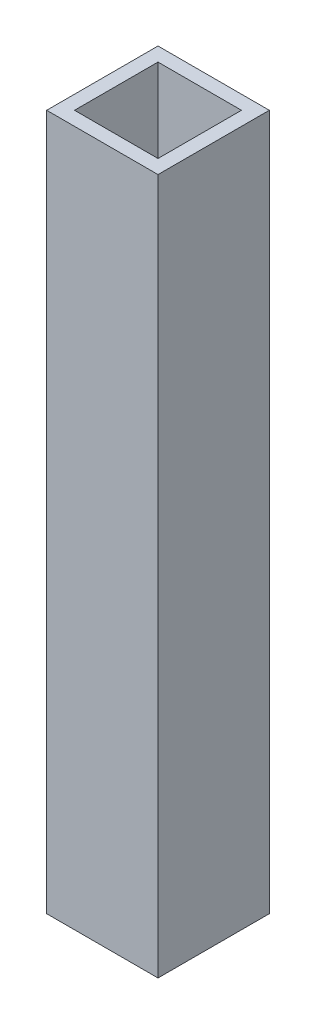
from build123d import *

# Parameters (mm, degrees)
SKETCH1_W           = 40
SKETCH1_H           = 40
SKETCH1_W_2         = 30
SKETCH1_H_2         = 30
BOSS_EXTRUDE1_DEPTH = 250


with BuildPart() as part:
    # Sketch1 → Boss-Extrude1 (new body)
    with BuildSketch(Plane(origin=(0, 0, 0), x_dir=(1, 0, 0), z_dir=(0, 1, 0))):
        with Locations((15, 15)):
            Rectangle(SKETCH1_W, SKETCH1_H)
        with Locations((15, 15)):
            Rectangle(SKETCH1_W_2, SKETCH1_H_2, mode=Mode.SUBTRACT)
    extrude(amount=BOSS_EXTRUDE1_DEPTH)


solid = part.part
